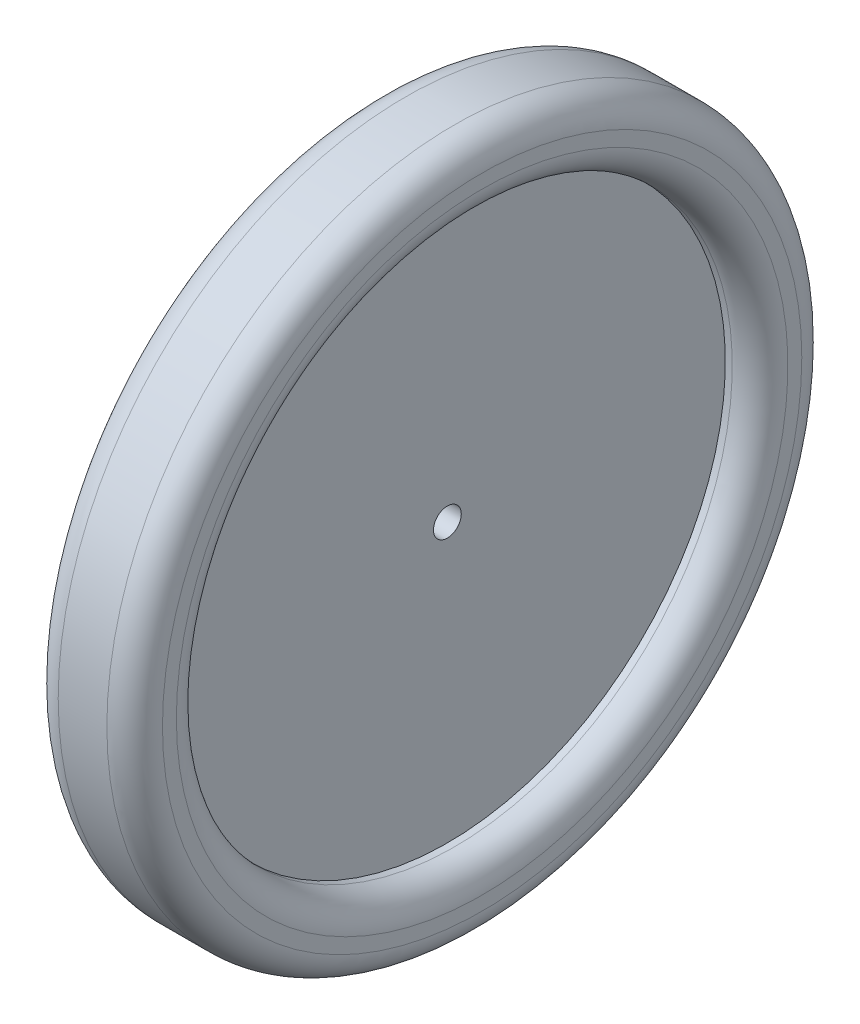
from build123d import *

# Parameters (mm, degrees)
SKETCH3_R          = 0.508
CUT_EXTRUDE1_DEPTH = 3.54


with BuildPart() as part:
    # Sketch2 → Revolve1 (revolve)
    with BuildSketch(Plane.XY):
        with BuildLine():
            Line((0.889, 12.7), (-0.889, 12.7))
            ThreePointArc((-0.889, 12.7), (-1.60742049, 12.40242049), (-1.905, 11.684))
            Line((-1.905, 11.684), (-1.905, 11.176))
            ThreePointArc((-1.905, 11.176), (-1.60742049, 10.45757951), (-0.889, 10.16))
            Line((-0.889, 10.16), (-0.635, 10.16))
            Line((-0.635, 10.16), (-0.635, 0))
            Line((-0.635, 0), (0.635, 0))
            Line((0.635, 0), (0.635, 10.16))
            Line((0.635, 10.16), (0.889, 10.16))
            ThreePointArc((0.889, 10.16), (1.60742049, 10.45757951), (1.905, 11.176))
            Line((1.905, 11.176), (1.905, 11.684))
            ThreePointArc((1.905, 11.684), (1.60742049, 12.40242049), (0.889, 12.7))
        make_face()
    revolve(axis=Axis((-0.635, 0, 0), (1, 0, 0)))

    # Sketch3 → Cut-Extrude1 (cut, through all)
    with BuildSketch(Plane(origin=(0.635, 0, 0), x_dir=(0, 0, -1), z_dir=(1, 0, 0))):
        Circle(SKETCH3_R)
    extrude(amount=-CUT_EXTRUDE1_DEPTH, mode=Mode.SUBTRACT)


solid = part.part
